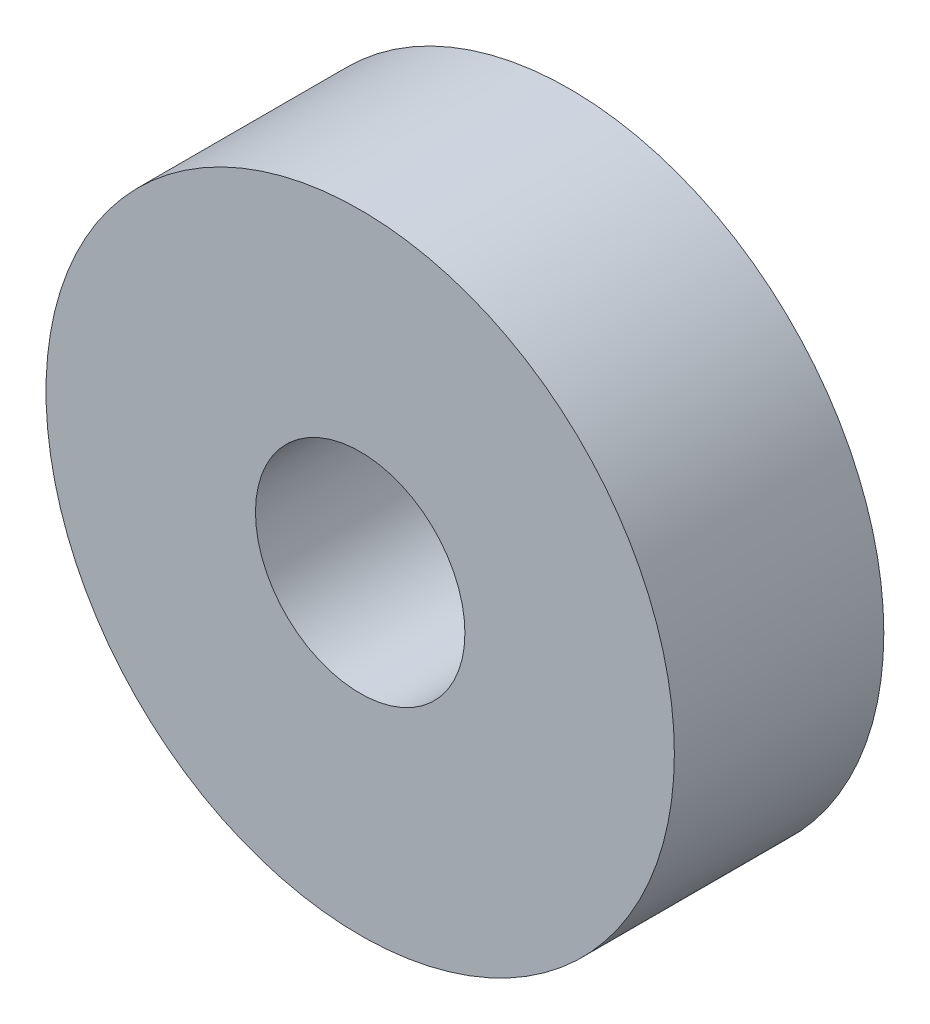
from build123d import *

# Parameters (mm, degrees)
SKETCH1_R           = 14.25
SKETCH1_R_2         = 4.75
BOSS_EXTRUDE1_DEPTH = 4.75


with BuildPart() as part:
    # Sketch1 → Boss-Extrude1 (new body, symmetric)
    with BuildSketch(Plane.XY):
        Circle(SKETCH1_R)
        Circle(SKETCH1_R_2, mode=Mode.SUBTRACT)
    extrude(amount=BOSS_EXTRUDE1_DEPTH, both=True)


solid = part.part
